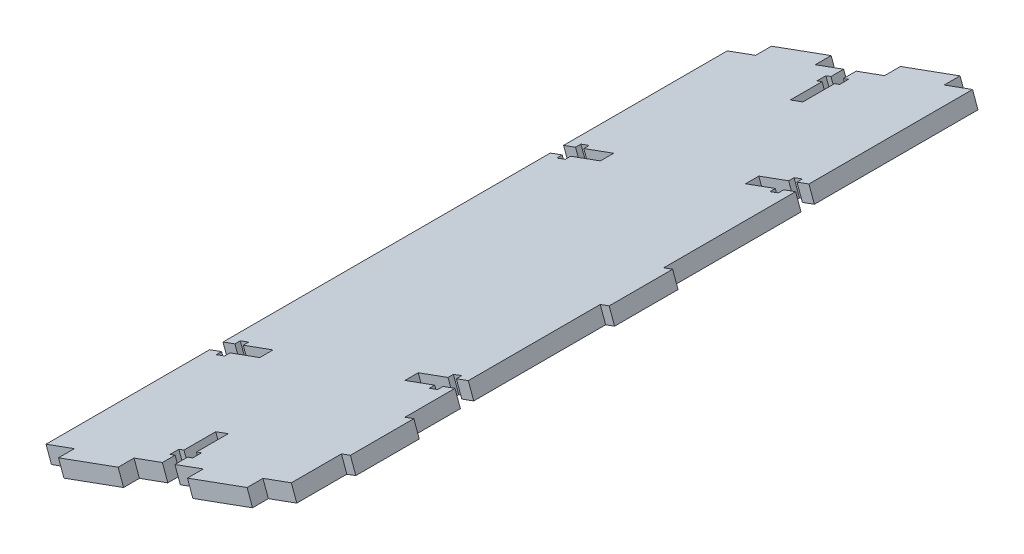
from build123d import *

# Parameters (mm, degrees)
BOSS_EXTRUDE1_DEPTH = 214.686455
CUT_EXTRUDE3_DEPTH  = 32.423010849
SKETCH5_W           = 20
SKETCH5_H           = 5
SKETCH5_W_2         = 3
SKETCH5_H_2         = 20
BOSS_EXTRUDE2_DEPTH = 5


with BuildPart() as part:
    # Sketch2 → Boss-Extrude1 (new body)
    with BuildSketch(Plane.XY.offset(4.949356739)):
        Polygon((-52.961538618, -36.862052104), (-51.252736373, -41.56098761), (-128.567156233, -69.67694155), (-130.275958479, -64.978006044), align=None)
    extrude(amount=BOSS_EXTRUDE1_DEPTH)

    # Sketch4 → Cut-Extrude3 (cut, through all)
    with BuildSketch(Plane(origin=(7.362313595, -20.245196221, 0), x_dir=(-0.939787101, -0.341760449, 0), z_dir=(0.341760449, -0.939787101, 0))):
        Polygon((101.40457011, -4.949356739), (105.60457011, -4.949356739), (105.60457011, -8.949356739), (107.30457011, -8.949356739), (107.30457011, -11.749356739), (105.60457011, -11.749356739), (105.60457011, -21.749356739), (101.40457011, -21.749356739), (101.40457011, -11.749356739), (99.70457011, -11.749356739), (99.70457011, -8.949356739), (101.40457011, -8.949356739), align=None)
        Polygon((62.37056233, -60.720970532), (62.37056233, -56.520970532), (66.37056233, -56.520970532), (66.37056233, -54.820970532), (69.17056233, -54.820970532), (69.17056233, -56.520970532), (79.17056233, -56.520970532), (79.17056233, -60.720970532), (69.17056233, -60.720970532), (69.17056233, -62.420970532), (66.37056233, -62.420970532), (66.37056233, -60.720970532), align=None)
        Polygon((105.60457011, -219.635811913), (101.40457011, -219.635811913), (101.40457011, -215.635811913), (99.70457011, -215.635811913), (99.70457011, -212.835811913), (101.40457011, -212.835811913), (101.40457011, -202.835811913), (105.60457011, -202.835811913), (105.60457011, -212.835811913), (107.30457011, -212.835811913), (107.30457011, -215.635811913), (105.60457011, -215.635811913), align=None)
        Polygon((66.37056233, -168.064198119), (66.37056233, -169.764198119), (69.17056233, -169.764198119), (69.17056233, -168.064198119), (79.17056233, -168.064198119), (79.17056233, -163.864198119), (69.17056233, -163.864198119), (69.17056233, -162.164198119), (66.37056233, -162.164198119), (66.37056233, -163.864198119), (62.37056233, -163.864198119), (62.37056233, -168.064198119), align=None)
        Polygon((144.638577891, -163.864198119), (144.638577891, -168.064198119), (140.638577891, -168.064198119), (140.638577891, -169.764198119), (137.838577891, -169.764198119), (137.838577891, -168.064198119), (127.838577891, -168.064198119), (127.838577891, -163.864198119), (137.838577891, -163.864198119), (137.838577891, -162.164198119), (140.638577891, -162.164198119), (140.638577891, -163.864198119), align=None)
        Polygon((140.638577891, -56.520970532), (140.638577891, -54.820970532), (137.838577891, -54.820970532), (137.838577891, -56.520970532), (127.838577891, -56.520970532), (127.838577891, -60.720970532), (137.838577891, -60.720970532), (137.838577891, -62.420970532), (140.638577891, -62.420970532), (140.638577891, -60.720970532), (144.638577891, -60.720970532), (144.638577891, -56.520970532), align=None)
    extrude(amount=-CUT_EXTRUDE3_DEPTH, mode=Mode.SUBTRACT)

    # Sketch5 → Boss-Extrude2 (add)
    with BuildSketch(Plane(origin=(7.362313595, -20.245196221, 0), x_dir=(0.939787101, 0.341760449, 0), z_dir=(0.341760449, -0.939787101, 0))):
        with Locations((-81.88756622, 2.449356739)):
            Rectangle(SKETCH5_W, SKETCH5_H)
        with Locations((-125.121574, 2.449356739)):
            Rectangle(SKETCH5_W, SKETCH5_H)
        with Locations((-60.87056233, 112.292584326)):
            Rectangle(SKETCH5_W_2, SKETCH5_H_2)
        with Locations((-60.87056233, 193.850005016)):
            Rectangle(SKETCH5_W_2, SKETCH5_H_2)
        with Locations((-81.88756622, 222.135811913)):
            Rectangle(SKETCH5_W, SKETCH5_H)
        with Locations((-125.121574, 222.135811913)):
            Rectangle(SKETCH5_W, SKETCH5_H)
    extrude(amount=-BOSS_EXTRUDE2_DEPTH)


solid = part.part
